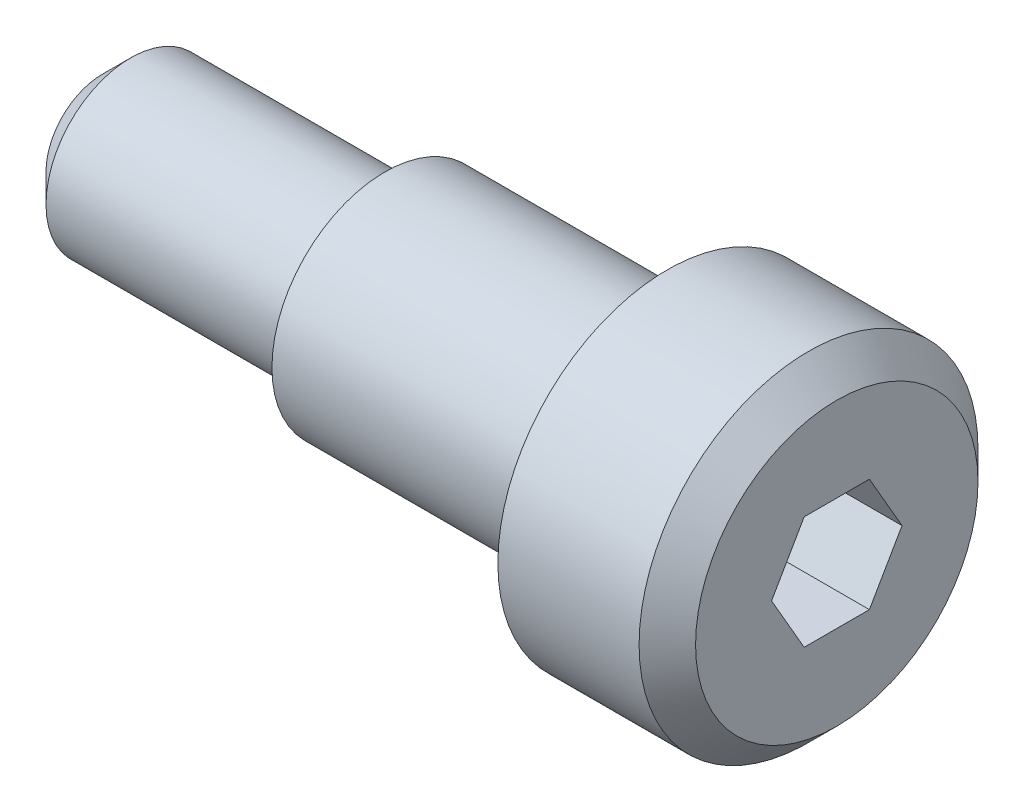
from build123d import *

# Parameters (mm, degrees)
CUT_EXTRUDE1_DEPTH = 4


with BuildPart() as part:
    # Sketch1 → Revolve1 (revolve)
    with BuildSketch(Plane.XY):
        Polygon((0, 0), (13, 0), (13, 2.5), (12.5, 3), (10, 3), (10, 2), (5, 2), (5, 1.5), (0.5, 1.5), (0, 1), align=None)
    revolve(axis=Axis((0, 0, 0), (1, 0, 0)))

    # Sketch2 → Cut-Extrude1 (cut)
    with BuildSketch(Plane(origin=(13, 0, 0), x_dir=(0, 0, -1), z_dir=(1, 0, 0))):
        Polygon((1.154700538, 0), (0.577350269, 1), (-0.577350269, 1), (-1.154700538, 0), (-0.577350269, -1), (0.577350269, -1), align=None)
    extrude(amount=-CUT_EXTRUDE1_DEPTH, mode=Mode.SUBTRACT)


solid = part.part
